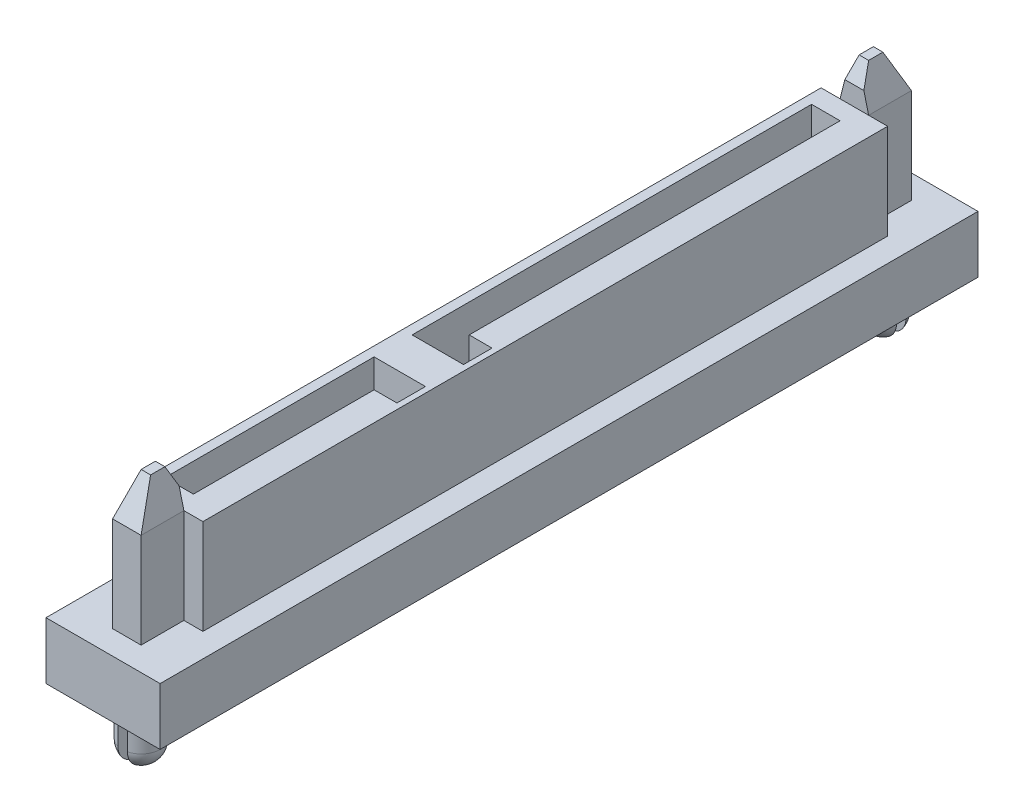
from build123d import *

# Parameters (mm, degrees)
SKETCH_1_W             = 6
SKETCH_1_H             = 43
EXTRUDE_1_DEPTH        = 10
SKETCH_3_R             = 1
EXTRUDE_2_DEPTH        = 3
FILLET_1_R             = 1
SKETCH_4_W             = 0.5
SKETCH_4_H             = 2
SKETCH_4_W_2           = 2
SKETCH_4_H_2           = 0.5
CUT_EXTRUDE_1_DEPTH    = 4
SKETCH_5_OUTSIDE_W     = 17.062
SKETCH_5_OUTSIDE_H     = 54.062
CUT_EXTRUDE_2_DEPTH    = 7
CUT_EXTRUDE_3_DEPTH    = 7
SKETCH_7_W             = 3.5
SKETCH_7_H             = 36
CUT_EXTRUDE_4_DEPTH    = 2
CHAMFER_1_SIZE         = 2
CHAMFER_1_SIZE2        = 0.5
CHAMFER_1_PART_2_SIZE  = 2
CHAMFER_1_PART_2_SIZE2 = 0.5
CHAMFER_2_SIZE         = 2
CHAMFER_2_SIZE2        = 0.5
CHAMFER_2_PART_2_SIZE  = 2
CHAMFER_2_PART_2_SIZE2 = 0.5
CHAMFER_3_SIZE         = 2
CHAMFER_3_SIZE2        = 1
CHAMFER_3_PART_2_SIZE  = 2
CHAMFER_3_PART_2_SIZE2 = 1
CHAMFER_4_SIZE         = 0.5
CHAMFER_4_SIZE2        = 1
CHAMFER_4_PART_2_SIZE  = 0.5
CHAMFER_4_PART_2_SIZE2 = 1


with BuildPart() as part:
    # 草图1 → 凸台-拉伸1 (new body)
    with BuildSketch(Plane(origin=(0, 0, 0), x_dir=(1, 0, 0), z_dir=(0, 1, 0))):
        Rectangle(SKETCH_1_W, SKETCH_1_H)
    extrude(amount=EXTRUDE_1_DEPTH)

    # 草图3 → 凸台-拉伸2 (add)
    with BuildSketch(Plane.XZ):
        with Locations((0, 19.5)):
            Circle(SKETCH_3_R)
        with Locations((0, -19.5)):
            Circle(SKETCH_3_R)
    extrude(amount=EXTRUDE_2_DEPTH)

    # 圆角1
    fillet_1_edges = [part.edges().sort_by_distance(p)[0] for p in [
        (-1, -3, 19.5),
        (-1, -3, -19.5),
    ]]
    fillet(fillet_1_edges, radius=FILLET_1_R)

    # 草图4 → 切除-拉伸1 (cut, through all)
    with BuildSketch(Plane.XZ):
        with Locations((0, 19.5)):
            Rectangle(SKETCH_4_W, SKETCH_4_H)
        with Locations((0, -19.5)):
            Rectangle(SKETCH_4_W_2, SKETCH_4_H_2)
    extrude(amount=CUT_EXTRUDE_1_DEPTH, mode=Mode.SUBTRACT)

    # 草图5 outside → 切除-拉伸2 (cut)
    with BuildSketch(Plane(origin=(0, 10, 0), x_dir=(1, 0, 0), z_dir=(0, 1, 0))):
        Rectangle(SKETCH_5_OUTSIDE_W, SKETCH_5_OUTSIDE_H)
        Polygon((-0.75, -20.25), (0.75, -20.25), (0.75, -18), (1.75, -18), (1.75, 18), (0.75, 18), (0.75, 20.25), (-0.75, 20.25), (-0.75, 18), (-1.75, 18), (-1.75, -18), (-0.75, -18), align=None, mode=Mode.SUBTRACT)
    extrude(amount=-CUT_EXTRUDE_2_DEPTH, mode=Mode.SUBTRACT)

    # 草图6 → 切除-拉伸3 (cut)
    with BuildSketch(Plane(origin=(0, 10, 0), x_dir=(1, 0, 0), z_dir=(0, 1, 0))):
        Polygon((-1.25, 17), (0.25, 17), (0.25, -2.5), (1.45, -2.5), (1.45, -4), (-1.25, -4), align=None)
        Polygon((-1.25, -17), (0.25, -17), (0.25, -7.5), (1.45, -7.5), (1.45, -6), (-1.25, -6), align=None)
    extrude(amount=-CUT_EXTRUDE_3_DEPTH, mode=Mode.SUBTRACT)

    # 草图7 → 切除-拉伸4 (cut)
    with BuildSketch(Plane(origin=(0, 10, 0), x_dir=(1, 0, 0), z_dir=(0, 1, 0))):
        Rectangle(SKETCH_7_W, SKETCH_7_H)
    extrude(amount=-CUT_EXTRUDE_4_DEPTH, mode=Mode.SUBTRACT)

    # 倒角1
    chamfer_1_edges = [part.edges().sort_by_distance(p)[0] for p in [
        (0.75, 10, -19.125),
    ]]
    chamfer_1_side = [part.faces().sort_by_distance(p)[0] for p in [
        (0.75, 6.5, -19.125),
    ]]
    chamfer(chamfer_1_edges, length=CHAMFER_1_SIZE, length2=CHAMFER_1_SIZE2, reference=chamfer_1_side[0])

    # 倒角1 part 2
    chamfer_1_part_2_edges = [part.edges().sort_by_distance(p)[0] for p in [
        (-0.75, 10, -19.125),
    ]]
    chamfer_1_part_2_side = [part.faces().sort_by_distance(p)[0] for p in [
        (-0.75, 6.5, -19.125),
    ]]
    chamfer(chamfer_1_part_2_edges, length=CHAMFER_1_PART_2_SIZE, length2=CHAMFER_1_PART_2_SIZE2, reference=chamfer_1_part_2_side[0])

    # 倒角2
    chamfer_2_edges = [part.edges().sort_by_distance(p)[0] for p in [
        (0.75, 10, 19.125),
    ]]
    chamfer_2_side = [part.faces().sort_by_distance(p)[0] for p in [
        (0.75, 6.5, 19.125),
    ]]
    chamfer(chamfer_2_edges, length=CHAMFER_2_SIZE, length2=CHAMFER_2_SIZE2, reference=chamfer_2_side[0])

    # 倒角2 part 2
    chamfer_2_part_2_edges = [part.edges().sort_by_distance(p)[0] for p in [
        (-0.75, 10, 19.125),
    ]]
    chamfer_2_part_2_side = [part.faces().sort_by_distance(p)[0] for p in [
        (-0.75, 6.5, 19.125),
    ]]
    chamfer(chamfer_2_part_2_edges, length=CHAMFER_2_PART_2_SIZE, length2=CHAMFER_2_PART_2_SIZE2, reference=chamfer_2_part_2_side[0])

    # 倒角3
    chamfer_3_edges = [part.edges().sort_by_distance(p)[0] for p in [
        (0, 10, -20.25),
    ]]
    chamfer_3_side = [part.faces().sort_by_distance(p)[0] for p in [
        (0, 6.201754386, -20.25),
    ]]
    chamfer(chamfer_3_edges, length=CHAMFER_3_SIZE, length2=CHAMFER_3_SIZE2, reference=chamfer_3_side[0])

    # 倒角3 part 2
    chamfer_3_part_2_edges = [part.edges().sort_by_distance(p)[0] for p in [
        (0, 10, 20.25),
    ]]
    chamfer_3_part_2_side = [part.faces().sort_by_distance(p)[0] for p in [
        (0, 6.201754386, 20.25),
    ]]
    chamfer(chamfer_3_part_2_edges, length=CHAMFER_3_PART_2_SIZE, length2=CHAMFER_3_PART_2_SIZE2, reference=chamfer_3_part_2_side[0])

    # 倒角4
    chamfer_4_edges = [part.edges().sort_by_distance(p)[0] for p in [
        (0, 10, -18),
    ]]
    chamfer_4_side = [part.faces().sort_by_distance(p)[0] for p in [
        (0, 10, -18.625),
    ]]
    chamfer(chamfer_4_edges, length=CHAMFER_4_SIZE, length2=CHAMFER_4_SIZE2, reference=chamfer_4_side[0])

    # 倒角4 part 2
    chamfer_4_part_2_edges = [part.edges().sort_by_distance(p)[0] for p in [
        (0, 10, 18),
    ]]
    chamfer_4_part_2_side = [part.faces().sort_by_distance(p)[0] for p in [
        (0, 10, 18.625),
    ]]
    chamfer(chamfer_4_part_2_edges, length=CHAMFER_4_PART_2_SIZE, length2=CHAMFER_4_PART_2_SIZE2, reference=chamfer_4_part_2_side[0])


solid = part.part
